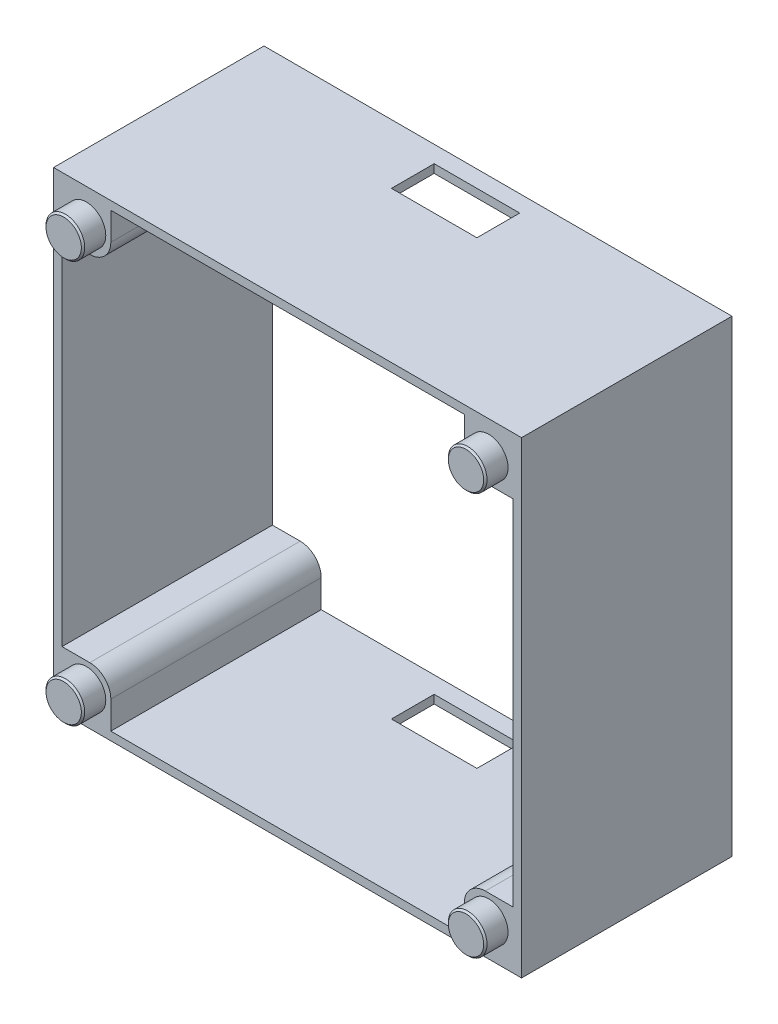
from build123d import *

# Parameters (mm, degrees)
SKICA1_W                 = 5.8
SKICA1_H                 = 5.8
SKICA1_W_2               = 1
SKICA1_H_2               = 42
SKICA1_W_3               = 42
SKICA1_H_3               = 1
P_IDAT_VYSUNUT_M2_DEPTH  = 25
ZAOBLIT1_R               = 2.5
SKICA2_R                 = 2.4
ODEBRAT_VYSUNUT_M1_DEPTH = 1.9
SKICA3_R                 = 2.3
P_IDAT_VYSUNUT_M3_DEPTH  = 2.7
ZKOSEN_1_SIZE            = 0.2
SKICA4_W                 = 10.16
SKICA4_H                 = 5.08
ODEBRAT_VYSUNUT_M2_DEPTH = 68.7


with BuildPart() as part:
    # Skica1 → Přidat vysunutím2 (new body)
    with BuildSketch(Plane.XY):
        Polygon((-27.8, 27.8), (-27.8, 21), (-26.8, 21), (-26.8, 26.8), (-21, 26.8), (-21, 27.8), align=None)
        with Locations((-23.9, 23.9)):
            Rectangle(SKICA1_W, SKICA1_H)
        Polygon((26.8, 21), (27.8, 21), (27.8, 27.8), (21, 27.8), (21, 26.8), (26.8, 26.8), align=None)
        with Locations((23.9, 23.9)):
            Rectangle(SKICA1_W, SKICA1_H)
        Polygon((21, -26.8), (21, -27.8), (27.8, -27.8), (27.8, -21), (26.8, -21), (26.8, -26.8), align=None)
        with Locations((23.9, -23.9)):
            Rectangle(SKICA1_W, SKICA1_H)
        with Locations((-23.9, -23.9)):
            Rectangle(SKICA1_W, SKICA1_H)
        Polygon((-27.8, -27.8), (-21, -27.8), (-21, -26.8), (-26.8, -26.8), (-26.8, -21), (-27.8, -21), align=None)
        with Locations((-27.3, 0)):
            Rectangle(SKICA1_W_2, SKICA1_H_2)
        with Locations((0, -27.3)):
            Rectangle(SKICA1_W_3, SKICA1_H_3)
        with Locations((27.3, 0)):
            Rectangle(SKICA1_W_2, SKICA1_H_2)
        with Locations((0, 27.3)):
            Rectangle(SKICA1_W_3, SKICA1_H_3)
    extrude(amount=P_IDAT_VYSUNUT_M2_DEPTH)

    # Zaoblit1
    zaoblit1_edges = [part.edges().sort_by_distance(p)[0] for p in [
        (21, -21, 12.5),
        (21, 21, 12.5),
        (-21, 21, 12.5),
        (-21, -21, 12.5),
    ]]
    fillet(zaoblit1_edges, radius=ZAOBLIT1_R)

    # Skica2 → Odebrat vysunutím1 (cut)
    with BuildSketch(Plane(origin=(0, 0, 0), x_dir=(-1, 0, 0), z_dir=(0, 0, -1))):
        with Locations((-23.9, 23.9)):
            Circle(SKICA2_R)
        with Locations((23.9, 23.9)):
            Circle(SKICA2_R)
        with Locations((23.9, -23.9)):
            Circle(SKICA2_R)
        with Locations((-23.9, -23.9)):
            Circle(SKICA2_R)
    extrude(amount=-ODEBRAT_VYSUNUT_M1_DEPTH, mode=Mode.SUBTRACT)

    # Skica3 → Přidat vysunutím3 (add)
    with BuildSketch(Plane.XY.offset(25)):
        with Locations((-23.9, 23.9)):
            Circle(SKICA3_R)
        with Locations((23.9, 23.9)):
            Circle(SKICA3_R)
        with Locations((23.9, -23.9)):
            Circle(SKICA3_R)
        with Locations((-23.9, -23.9)):
            Circle(SKICA3_R)
    extrude(amount=P_IDAT_VYSUNUT_M3_DEPTH)

    # Zkosení1
    zkosen_1_edges = [part.edges().sort_by_distance(p)[0] for p in [
        (-26.2, 23.9, 27.7),
        (21.6, 23.9, 27.7),
        (21.6, -23.9, 27.7),
        (-26.2, -23.9, 27.7),
    ]]
    chamfer(zkosen_1_edges, length=ZKOSEN_1_SIZE)

    # Skica4 → Odebrat vysunutím2 (cut)
    with BuildSketch(Plane(origin=(0, -27.8, 0), x_dir=(-1, 0, 0), z_dir=(0, -1, 0))):
        with Locations((0.5, -4.54)):
            Rectangle(SKICA4_W, SKICA4_H)
    extrude(amount=-ODEBRAT_VYSUNUT_M2_DEPTH, mode=Mode.SUBTRACT)


solid = part.part
